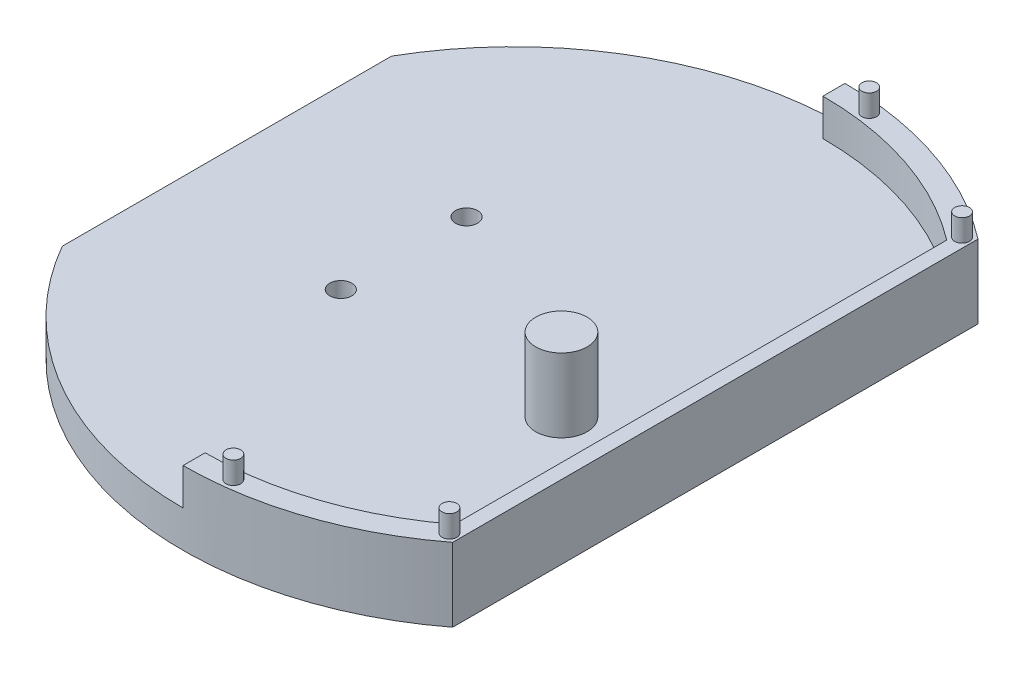
from build123d import *

# Parameters (mm, degrees)
SKETCH_1_R      = 1.5
EXTRUDE_1_DEPTH = 5
SKETCH_2_R      = 3.5
EXTRUDE_2_DEPTH = 10
EXTRUDE_3_DEPTH = 5
SKETCH_4_R      = 1
EXTRUDE_4_DEPTH = 3


with BuildPart() as part:
    # 草图1 → 凸台-拉伸1 (new body)
    with BuildSketch(Plane(origin=(0, 0, 0), x_dir=(1, 0, 0), z_dir=(0, 1, 0))):
        with BuildLine():
            Line((-39.038561358, -22.382822144), (-39.038561358, 22.382822144))
            ThreePointArc((-39.038561358, 22.382822144), (-8.857541047, 44.119655105), (27.374530931, 35.716033603))
            Line((27.374530931, 35.716033603), (27.374530931, -35.716033603))
            ThreePointArc((27.374530931, -35.716033603), (-8.857541047, -44.119655105), (-39.038561358, -22.382822144))
        make_face()
        with Locations((-15, 8.55)):
            Circle(SKETCH_1_R, mode=Mode.SUBTRACT)
        with Locations((-15, -8.55)):
            Circle(SKETCH_1_R, mode=Mode.SUBTRACT)
    extrude(amount=EXTRUDE_1_DEPTH)

    # 草图2 → 凸台-拉伸2 (add)
    with BuildSketch(Plane(origin=(0, 5, 0), x_dir=(1, 0, 0), z_dir=(0, 1, 0))):
        with Locations((15, -8.55)):
            Circle(SKETCH_2_R)
    extrude(amount=EXTRUDE_2_DEPTH)

    # 草图3 → 凸台-拉伸3 (add)
    with BuildSketch(Plane(origin=(0, 5, 0), x_dir=(1, 0, 0), z_dir=(0, 1, 0))):
        with BuildLine():
            ThreePointArc((0, -45), (13.278516311, -42.996290591), (25.374530931, -37.163600203))
            Line((25.374530931, -37.163600203), (25.374530931, -33.46839076))
            ThreePointArc((25.374530931, -33.46839076), (13.385208031, -39.810001331), (0, -42))
            Line((0, -42), (0, -45))
        make_face()
        with BuildLine():
            Line((25.374530931, -33.46839076), (25.374530931, -37.163600203))
            ThreePointArc((25.374530931, -37.163600203), (26.384460277, -36.453535575), (27.374530931, -35.716033603))
            Line((27.374530931, -35.716033603), (27.374530931, -31.853336659))
            ThreePointArc((27.374530931, -31.853336659), (26.386890339, -32.676168965), (25.374530931, -33.46839076))
        make_face()
        with BuildLine():
            Line((25.374530931, 33.46839076), (25.374530931, -33.46839076))
            ThreePointArc((25.374530931, -33.46839076), (26.386890339, -32.676168965), (27.374530931, -31.853336659))
            Line((27.374530931, -31.853336659), (27.374530931, 31.853336659))
            ThreePointArc((27.374530931, 31.853336659), (26.386890339, 32.676168965), (25.374530931, 33.46839076))
        make_face()
        with BuildLine():
            Line((25.374530931, 37.163600203), (25.374530931, 33.46839076))
            ThreePointArc((25.374530931, 33.46839076), (26.386890339, 32.676168965), (27.374530931, 31.853336659))
            Line((27.374530931, 31.853336659), (27.374530931, 35.716033603))
            ThreePointArc((27.374530931, 35.716033603), (26.384460277, 36.453535575), (25.374530931, 37.163600203))
        make_face()
        with BuildLine():
            ThreePointArc((0, 42), (13.385208031, 39.810001331), (25.374530931, 33.46839076))
            Line((25.374530931, 33.46839076), (25.374530931, 37.163600203))
            ThreePointArc((25.374530931, 37.163600203), (13.278516311, 42.996290591), (0, 45))
            Line((0, 45), (0, 42))
        make_face()
    extrude(amount=EXTRUDE_3_DEPTH)

    # 草图4 → 凸台-拉伸4 (add)
    with BuildSketch(Plane(origin=(0, 10, 0), x_dir=(1, 0, 0), z_dir=(0, 1, 0))):
        with Locations((26.074530931, -34.848835383)):
            Circle(SKETCH_4_R)
        with Locations((5.074530931, -43.226977996)):
            Circle(SKETCH_4_R)
        with Locations((26.074530931, 34.848835383)):
            Circle(SKETCH_4_R)
        with Locations((5.074530931, 43.226977996)):
            Circle(SKETCH_4_R)
    extrude(amount=EXTRUDE_4_DEPTH)


solid = part.part
